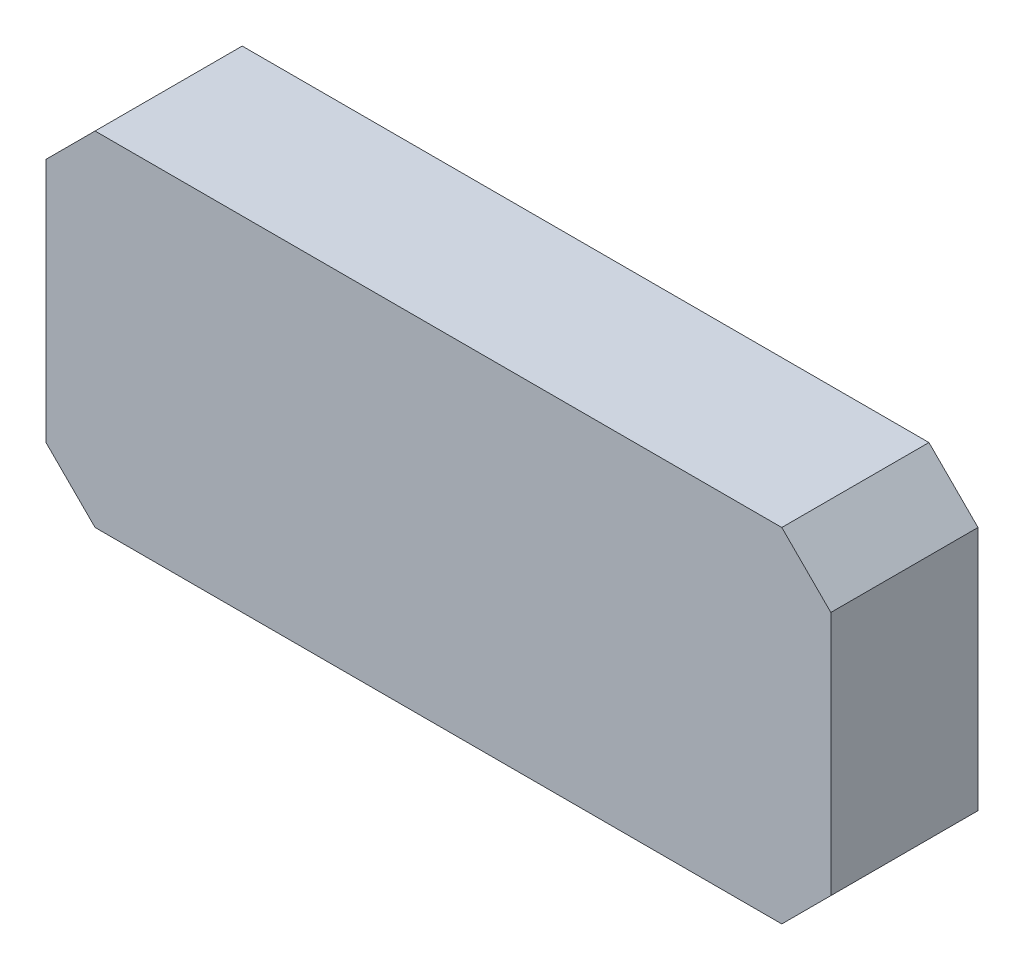
from build123d import *

# Parameters (mm, degrees)
SKETCH_1_W      = 16
SKETCH_1_H      = 7
EXTRUDE_1_DEPTH = 3
CHAMFER_2_SIZE  = 1


with BuildPart() as part:
    # Эскиз1 → Вытянуть1 (new body)
    with BuildSketch(Plane.XY):
        with Locations((0, 0.5)):
            Rectangle(SKETCH_1_W, SKETCH_1_H)
    extrude(amount=EXTRUDE_1_DEPTH)

    # Фаска2
    chamfer_2_edges = [part.edges().sort_by_distance(p)[0] for p in [
        (-8, 4, 1.5),
        (8, 4, 1.5),
        (8, -3, 1.5),
        (-8, -3, 1.5),
    ]]
    chamfer(chamfer_2_edges, length=CHAMFER_2_SIZE)


solid = part.part
